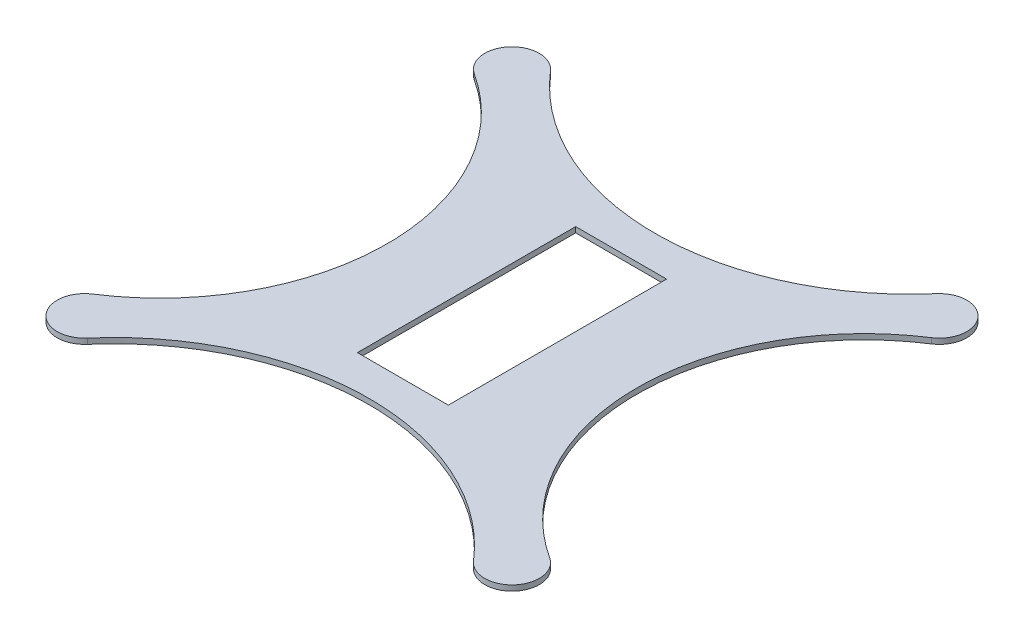
from build123d import *

# Parameters (mm, degrees)
SKETCH4_W           = 50
SKETCH4_H           = 120
BOSS_EXTRUDE1_DEPTH = 3


with BuildPart() as part:
    # Sketch4 → Boss-Extrude1 (new body)
    with BuildSketch(Plane(origin=(0, 0, 0), x_dir=(1, 0, 0), z_dir=(0, 1, 0))):
        with BuildLine():
            ThreePointArc((-106.129032258, 127.282693525), (-128.800946783, 127.363498456), (-125.655359293, 104.910714286))
            ThreePointArc((-125.655359293, 104.910714286), (-68.616686738, 0), (-125.655359293, -104.910714286))
            ThreePointArc((-125.655359293, -104.910714286), (-128.800946783, -127.363498456), (-106.129032258, -127.282693525))
            ThreePointArc((-106.129032258, -127.282693525), (0, -78.587833096), (106.129032258, -127.282693525))
            ThreePointArc((106.129032258, -127.282693525), (128.800946783, -127.363498456), (125.655359293, -104.910714286))
            ThreePointArc((125.655359293, -104.910714286), (68.616686738, 0), (125.655359293, 104.910714286))
            ThreePointArc((125.655359293, 104.910714286), (128.800946783, 127.363498456), (106.129032258, 127.282693525))
            ThreePointArc((106.129032258, 127.282693525), (0, 78.587833096), (-106.129032258, 127.282693525))
        make_face()
        Rectangle(SKETCH4_W, SKETCH4_H, mode=Mode.SUBTRACT)
    extrude(amount=BOSS_EXTRUDE1_DEPTH)


solid = part.part
